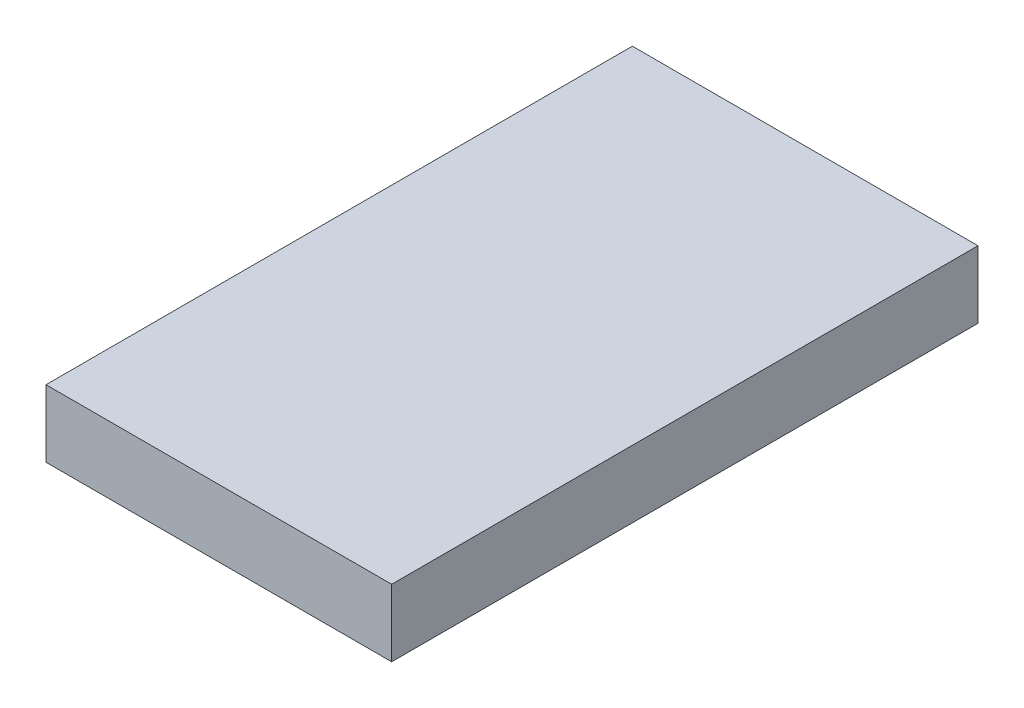
from build123d import *

# Parameters (mm, degrees)
SKETCH1_W           = 24.7
SKETCH1_H           = 41.9
BOSS_EXTRUDE1_DEPTH = 4.8


with BuildPart() as part:
    # Sketch1 → Boss-Extrude1 (new body)
    with BuildSketch(Plane(origin=(0, 0, 0), x_dir=(1, 0, 0), z_dir=(0, 1, 0))):
        with Locations((12.35, 20.95)):
            Rectangle(SKETCH1_W, SKETCH1_H)
    extrude(amount=BOSS_EXTRUDE1_DEPTH)


solid = part.part
